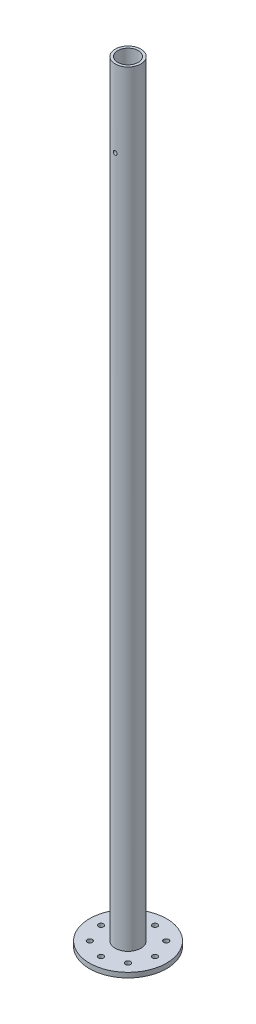
from build123d import *

# Parameters (mm, degrees)
SKETCH1_R                      = 16.7
SKETCH1_R_2                    = 13.32
BOSS_EXTRUDE1_DEPTH            = 1000
SKETCH13_R                     = 50
SKETCH13_R_2                   = 16.7
BOSS_EXTRUDE2_DEPTH            = 6.35
F_1_4_CLEARANCE_HOLE1_D        = 6.7564
F_1_4_CLEARANCE_HOLE1_DEPTH    = 50
F_8_0_199_DIAMETER_HOLE6_D     = 5.0546
F_8_0_199_DIAMETER_HOLE6_DEPTH = 50


with BuildPart() as part:
    # Sketch1 → Boss-Extrude1 (new body)
    with BuildSketch(Plane(origin=(0, 0, 0), x_dir=(1, 0, 0), z_dir=(0, 1, 0))):
        Circle(SKETCH1_R)
        Circle(SKETCH1_R_2, mode=Mode.SUBTRACT)
    extrude(amount=BOSS_EXTRUDE1_DEPTH)

    # Sketch13 → Boss-Extrude2 (add)
    with BuildSketch(Plane(origin=(0, 0, 0), x_dir=(-1, 0, 0), z_dir=(0, -1, 0))):
        Circle(SKETCH13_R)
        Circle(SKETCH13_R_2, mode=Mode.SUBTRACT)
    extrude(amount=-BOSS_EXTRUDE2_DEPTH)

    # 1/4 Clearance Hole1
    with Locations(Plane(origin=(0, 0, 0), x_dir=(-1, 0, 0), z_dir=(0, -1, 0))):
        with Locations((-35, 0), (0, 35), (35, 0), (0, -35), (24.748737342, 24.748737342), (24.748737342, -24.748737342), (-24.748737342, -24.748737342), (-24.748737342, 24.748737342)):
            Hole(F_1_4_CLEARANCE_HOLE1_D / 2, depth=F_1_4_CLEARANCE_HOLE1_DEPTH)

    # #8 (0.199) Diameter Hole6
    with Locations(Plane(origin=(0, 900, -16.7), x_dir=(-1, 0, 0), z_dir=(0, 0, -1))):
        with Locations((0, 0)):
            Hole(F_8_0_199_DIAMETER_HOLE6_D / 2, depth=F_8_0_199_DIAMETER_HOLE6_DEPTH)


solid = part.part
